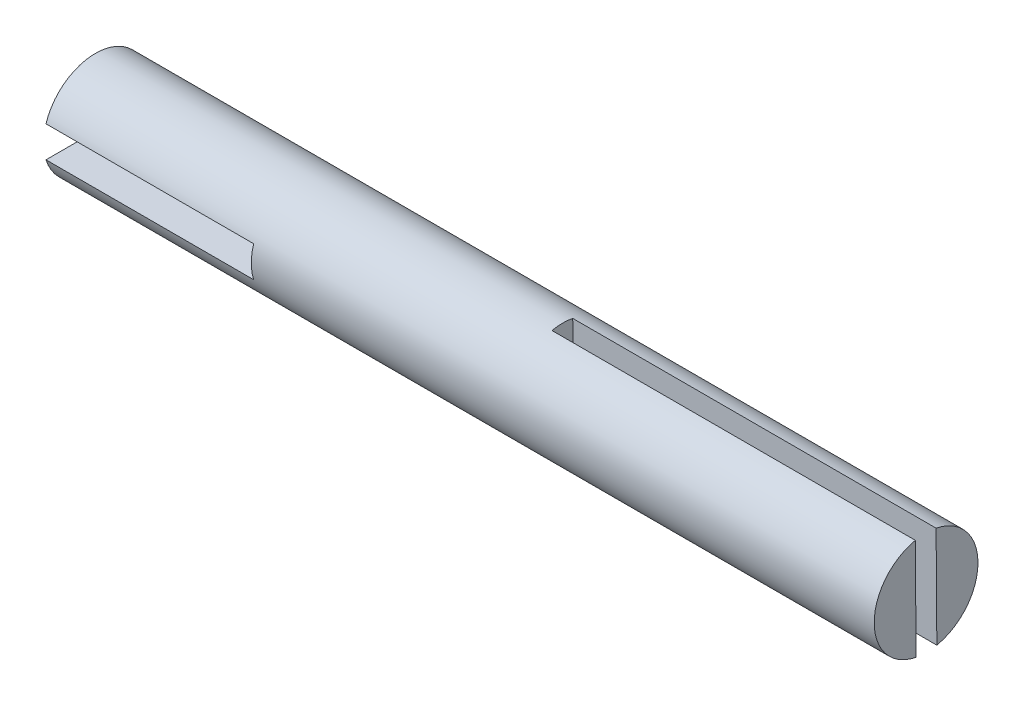
from build123d import *

# Parameters (mm, degrees)
SKETCH_1_R          = 5
EXTRUDE_1_DEPTH     = 80
SKETCH_2_W          = 13.601077261
SKETCH_2_H          = 3
CUT_EXTRUDE_1_DEPTH = 20
CUT_EXTRUDE_2_DEPTH = 35


with BuildPart() as part:
    # 草图1 → 凸台-拉伸1 (new body)
    with BuildSketch(Plane(origin=(0, 0, 0), x_dir=(0, 0, -1), z_dir=(1, 0, 0))):
        Circle(SKETCH_1_R)
    extrude(amount=EXTRUDE_1_DEPTH)

    # 草图2 → 切除-拉伸1 (cut)
    with BuildSketch(Plane(origin=(0, 0, 0), x_dir=(0, 0, -1), z_dir=(1, 0, 0))):
        with Locations((0.220015061, 0)):
            Rectangle(SKETCH_2_W, SKETCH_2_H)
    extrude(amount=CUT_EXTRUDE_1_DEPTH, mode=Mode.SUBTRACT)

    # 草图3 → 切除-拉伸2 (cut)
    with BuildSketch(Plane(origin=(80, 0, 0), x_dir=(0, 0, -1), z_dir=(1, 0, 0))):
        Polygon((-0.999943638, -0.009058055), (-0.914206616, -12.008751766), (1.085793384, -11.994461897), (0.91431934, 12.004925525), (-1.08568066, 11.990635657), align=None)
    extrude(amount=-CUT_EXTRUDE_2_DEPTH, mode=Mode.SUBTRACT)


solid = part.part
